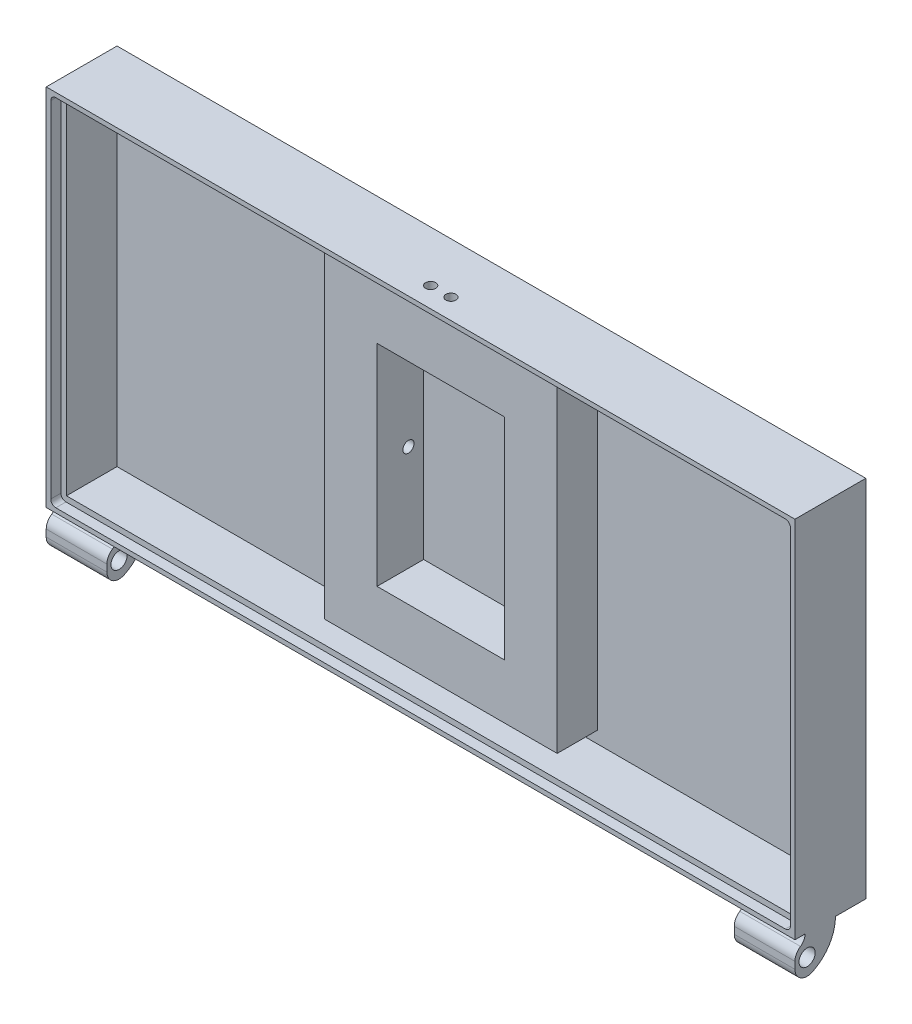
from build123d import *

# Parameters (mm, degrees)
SKETCH1_W                      = 370
SKETCH1_H                      = 180
BOSS_EXTRUDE1_DEPTH            = 35
SKETCH2_W                      = 365.5
SKETCH2_H                      = 175.5
CUT_EXTRUDE1_DEPTH             = 5
SKETCH3_W                      = 360
SKETCH3_H                      = 170
CUT_EXTRUDE2_DEPTH             = 25
SKETCH4_W                      = 115
SKETCH4_H                      = 20
BOSS_EXTRUDE2_DEPTH            = 170
SKETCH5_W                      = 105
SKETCH5_H                      = 148
CUT_EXTRUDE3_DEPTH             = 18
SKETCH6_W                      = 73
SKETCH6_H                      = 114
BOSS_EXTRUDE3_DEPTH            = 18
F_15_0_15_DIAMETER_HOLE1_D     = 5.5
F_15_0_15_DIAMETER_HOLE1_DEPTH = 11
FILLET1_R                      = 2.5
FILLET2_R                      = 15
SKETCH11_W                     = 30
SKETCH11_H                     = 15
REVOLVE1_ANGLE                 = 90
SKETCH12_R                     = 4
CUT_EXTRUDE4_DEPTH             = 371
FILLET4_R                      = 6
FILLET5_R                      = 6
SKETCH13_W                     = 63
SKETCH13_H                     = 104
CUT_EXTRUDE5_DEPTH             = 23
CUT_EXTRUDE6_START             = -20
SKETCH14_W                     = 115
SKETCH14_H                     = 6
CUT_EXTRUDE6_DEPTH             = 20
CUT_EXTRUDE7_START             = -20
SKETCH15_W                     = 115
SKETCH15_H                     = 6
CUT_EXTRUDE7_DEPTH             = 20
CUT_EXTRUDE8_REACH             = 200.649
SKETCH17_R                     = 2.5
SKETCH18_R                     = 2.75
CUT_EXTRUDE9_DEPTH             = 10


with BuildPart() as part:
    # Sketch1 → Boss-Extrude1 (new body)
    with BuildSketch(Plane.XY.offset(35)):
        with Locations((185, 90)):
            Rectangle(SKETCH1_W, SKETCH1_H)
    extrude(amount=-BOSS_EXTRUDE1_DEPTH)

    # Sketch2 → Cut-Extrude1 (cut)
    with BuildSketch(Plane.XY.offset(35)):
        with Locations((185, 90)):
            Rectangle(SKETCH2_W, SKETCH2_H)
    extrude(amount=-CUT_EXTRUDE1_DEPTH, mode=Mode.SUBTRACT)

    # Sketch3 → Cut-Extrude2 (cut)
    with BuildSketch(Plane.XY.offset(30)):
        with Locations((185, 90)):
            Rectangle(SKETCH3_W, SKETCH3_H)
    extrude(amount=-CUT_EXTRUDE2_DEPTH, mode=Mode.SUBTRACT)

    # Sketch4 → Boss-Extrude2 (add)
    with BuildSketch(Plane(origin=(0, 5, 0), x_dir=(-1, 0, 0), z_dir=(0, 1, 0))):
        with Locations((-185, 15)):
            Rectangle(SKETCH4_W, SKETCH4_H)
    extrude(amount=BOSS_EXTRUDE2_DEPTH)

    # Sketch5 → Cut-Extrude3 (cut)
    with BuildSketch(Plane(origin=(0, 0, 0), x_dir=(-1, 0, 0), z_dir=(0, 0, -1))):
        with Locations((-185, 90)):
            Rectangle(SKETCH5_W, SKETCH5_H)
    extrude(amount=-CUT_EXTRUDE3_DEPTH, mode=Mode.SUBTRACT)

    # Sketch6 → Boss-Extrude3 (add)
    with BuildSketch(Plane(origin=(0, 0, 18), x_dir=(-1, 0, 0), z_dir=(0, 0, -1))):
        with Locations((-185, 90)):
            Rectangle(SKETCH6_W, SKETCH6_H)
    extrude(amount=BOSS_EXTRUDE3_DEPTH)

    # Ø15.0 (15) Diameter Hole1
    with Locations(Plane.ZY.offset(-148.5)):
        with Locations((9.5, 90)):
            Hole(F_15_0_15_DIAMETER_HOLE1_D / 2, depth=F_15_0_15_DIAMETER_HOLE1_DEPTH)

    # Fillet1
    fillet1_edges = [part.edges().sort_by_distance(p)[0] for p in [
        (2.25, 177.75, 32.5),
        (367.75, 177.75, 32.5),
        (367.75, 2.25, 32.5),
        (2.25, 2.25, 32.5),
    ]]
    fillet(fillet1_edges, radius=FILLET1_R)

    # Fillet2
    fillet2_edges = [part.edges().sort_by_distance(p)[0] for p in [
        (132.5, 16, 9),
        (237.5, 16, 9),
        (237.5, 164, 9),
        (132.5, 164, 9),
        (148.5, 147, 9),
        (221.5, 147, 9),
        (221.5, 33, 9),
        (148.5, 33, 9),
    ]]
    fillet(fillet2_edges, radius=FILLET2_R)

    # Sketch11 → Revolve1 (revolve)
    with BuildSketch(Plane.XY.offset(35)):
        with Locations((355, -12.5)):
            Rectangle(SKETCH11_W, SKETCH11_H)
        with Locations((15, -12.5)):
            Rectangle(SKETCH11_W, SKETCH11_H)
    revolve(axis=Axis((0, 0, 35), (1, 0, 0)), revolution_arc=REVOLVE1_ANGLE)

    # Sketch12 → Cut-Extrude4 (cut, through all)
    with BuildSketch(Plane(origin=(370, 0, 0), x_dir=(0, 0, -1), z_dir=(1, 0, 0))):
        with Locations((-29, -10.5)):
            Circle(SKETCH12_R)
    extrude(amount=-CUT_EXTRUDE4_DEPTH, mode=Mode.SUBTRACT)

    # Fillet4
    fillet4_edges = [part.edges().sort_by_distance(p)[0] for p in [
        (355, -20, 35),
        (15, -20, 35),
    ]]
    fillet(fillet4_edges, radius=FILLET4_R)

    # Fillet5
    fillet5_edges = [part.edges().sort_by_distance(p)[0] for p in [
        (355, -5, 35),
        (15, -5, 35),
    ]]
    fillet(fillet5_edges, radius=FILLET5_R)

    # Sketch13 → Cut-Extrude5 (cut)
    with BuildSketch(Plane.XY.offset(25)):
        with Locations((185, 90)):
            Rectangle(SKETCH13_W, SKETCH13_H)
    extrude(amount=-CUT_EXTRUDE5_DEPTH, mode=Mode.SUBTRACT)

    # Sketch14 → Cut-Extrude6 (cut)
    with BuildSketch(Plane.XY.offset(25).offset(CUT_EXTRUDE6_START)):
        with Locations((185, 172)):
            Rectangle(SKETCH14_W, SKETCH14_H)
    extrude(amount=CUT_EXTRUDE6_DEPTH, mode=Mode.SUBTRACT)

    # Sketch15 → Cut-Extrude7 (cut)
    with BuildSketch(Plane.XY.offset(25).offset(CUT_EXTRUDE7_START)):
        with Locations((185, 8)):
            Rectangle(SKETCH15_W, SKETCH15_H)
    extrude(amount=CUT_EXTRUDE7_DEPTH, mode=Mode.SUBTRACT)

    # Sketch17 → Cut-Extrude8 (cut, up to next)
    with BuildSketch(Plane(origin=(0, 180, 0), x_dir=(1, 0, 0), z_dir=(0, 1, 0)), mode=Mode.PRIVATE) as cut_extrude8_sk1:
        with Locations((180, -25)):
            Circle(SKETCH17_R)
    cut_extrude8_tool1 = extrude(cut_extrude8_sk1.sketch, amount=-CUT_EXTRUDE8_REACH, mode=Mode.PRIVATE) & part.part
    add(cut_extrude8_tool1.solids().sort_by_distance((180, 180, 25))[0], mode=Mode.SUBTRACT)
    # Sketch17 → Cut-Extrude8 (cut, up to next)
    with BuildSketch(Plane(origin=(0, 180, 0), x_dir=(1, 0, 0), z_dir=(0, 1, 0)), mode=Mode.PRIVATE) as cut_extrude8_sk2:
        with Locations((190, -25)):
            Circle(SKETCH17_R)
    cut_extrude8_tool2 = extrude(cut_extrude8_sk2.sketch, amount=-CUT_EXTRUDE8_REACH, mode=Mode.PRIVATE) & part.part
    add(cut_extrude8_tool2.solids().sort_by_distance((190, 180, 25))[0], mode=Mode.SUBTRACT)

    # Sketch18 → Cut-Extrude9 (cut)
    with BuildSketch(Plane(origin=(221.5, 0, 0), x_dir=(0, 0, -1), z_dir=(1, 0, 0))):
        with Locations((-9.5, 90)):
            Circle(SKETCH18_R)
    extrude(amount=-CUT_EXTRUDE9_DEPTH, mode=Mode.SUBTRACT)


solid = part.part
